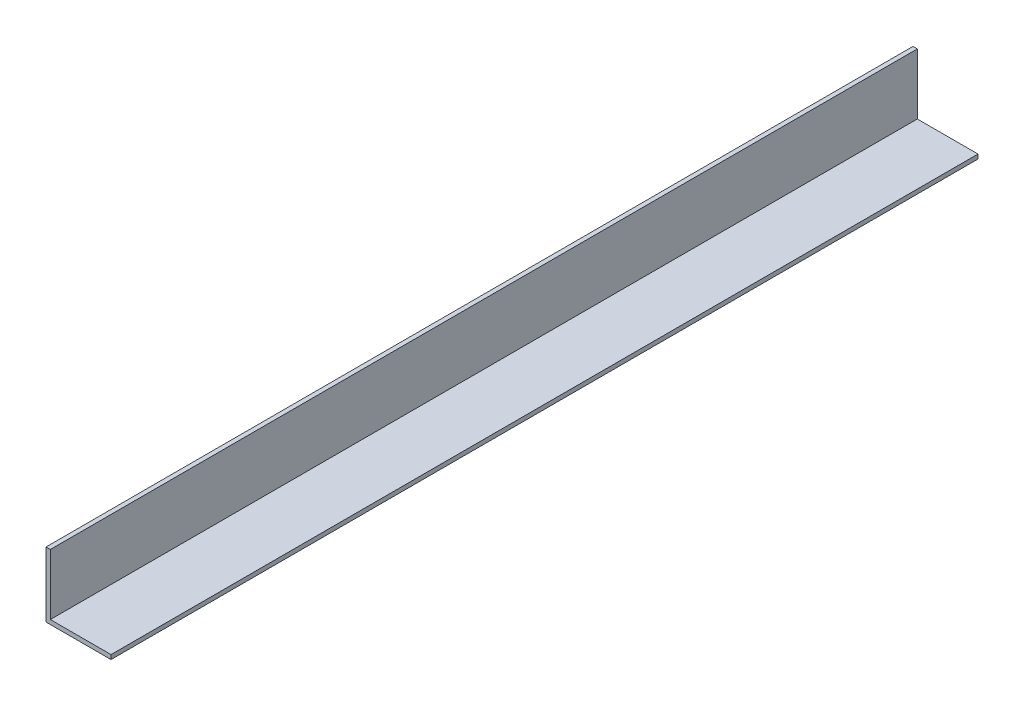
from build123d import *

# Parameters (mm, degrees)
EXTRUDE_1_DEPTH = 200


with BuildPart() as part:
    # Эскиз1 → Бобышка-Вытянуть1 (new body)
    with BuildSketch(Plane.XY):
        Polygon((0, 0), (15, 0), (15, 1), (1, 1), (1, 15), (0, 15), align=None)
    extrude(amount=EXTRUDE_1_DEPTH)


solid = part.part
